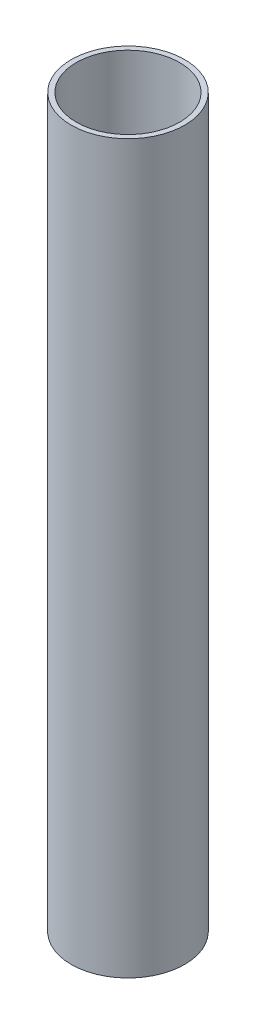
from build123d import *

# Parameters (mm, degrees)
SKETCH1_R           = 7.9375
SKETCH1_R_2         = 7.2263
BOSS_EXTRUDE1_DEPTH = 101.6


with BuildPart() as part:
    # Sketch1 → Boss-Extrude1 (new body)
    with BuildSketch(Plane(origin=(0, 0, 0), x_dir=(1, 0, 0), z_dir=(0, 1, 0))):
        Circle(SKETCH1_R)
        Circle(SKETCH1_R_2, mode=Mode.SUBTRACT)
    extrude(amount=BOSS_EXTRUDE1_DEPTH)


solid = part.part
